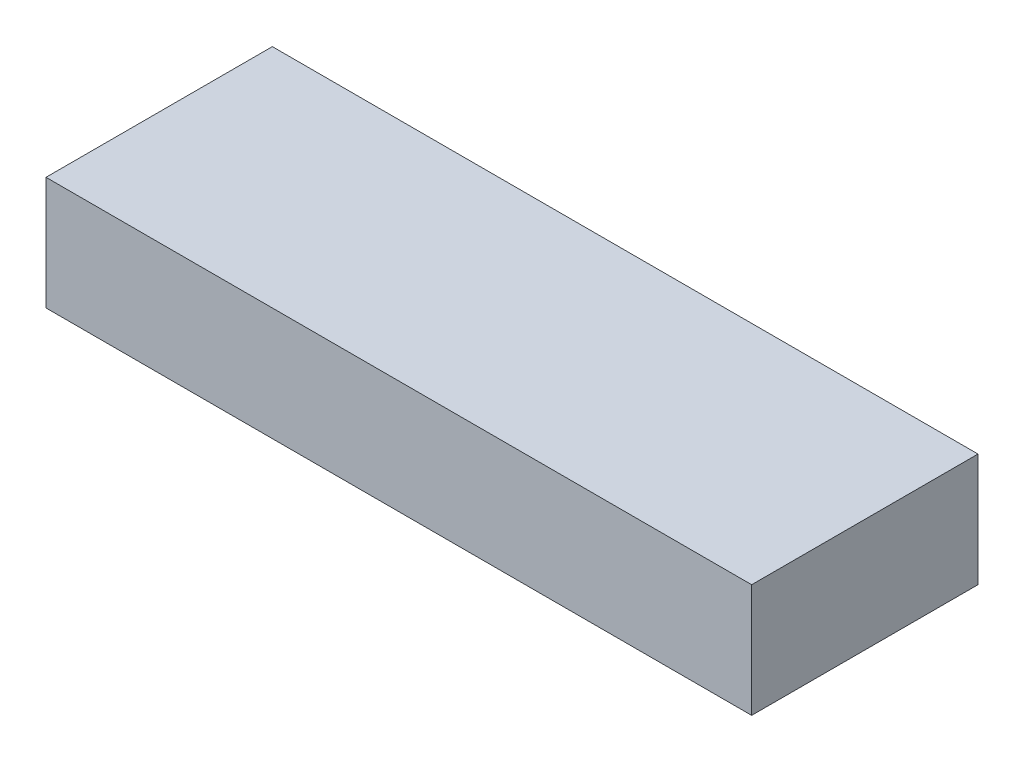
from build123d import *

# Parameters (mm, degrees)
SKETCH1_W           = 106
SKETCH1_H           = 34.000000072
BOSS_EXTRUDE1_DEPTH = 17


with BuildPart() as part:
    # Sketch1 → Boss-Extrude1 (new body)
    with BuildSketch(Plane(origin=(0, 0, 0), x_dir=(1, 0, 0), z_dir=(0, 1, 0))):
        Rectangle(SKETCH1_W, SKETCH1_H)
    extrude(amount=BOSS_EXTRUDE1_DEPTH)


solid = part.part
